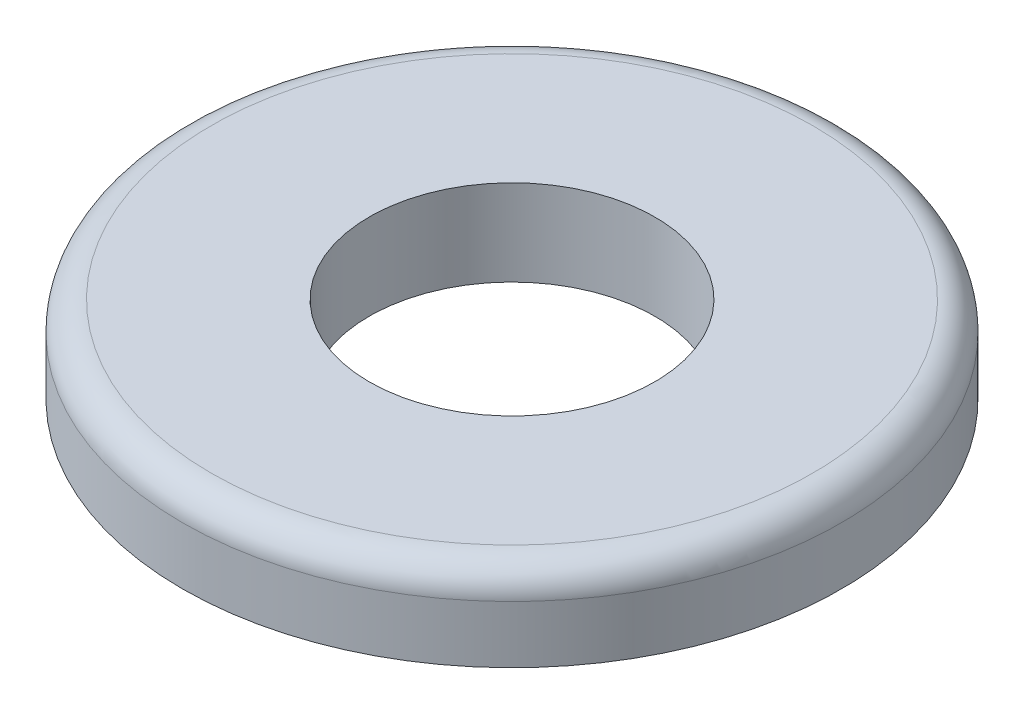
from build123d import *

# Parameters (mm, degrees)
SKETCH1_R           = 18.25625
SKETCH1_R_2         = 7.9121
BOSS_EXTRUDE1_DEPTH = 4.7625
FILLET1_R           = 1.5875


with BuildPart() as part:
    # Sketch1 → Boss-Extrude1 (new body)
    with BuildSketch(Plane(origin=(0, 0, 0), x_dir=(1, 0, 0), z_dir=(0, 1, 0))):
        Circle(SKETCH1_R)
        Circle(SKETCH1_R_2, mode=Mode.SUBTRACT)
    extrude(amount=BOSS_EXTRUDE1_DEPTH)

    # Fillet1
    fillet1_edges = [part.edges().sort_by_distance(p)[0] for p in [
        (-18.25625, 4.7625, 0),
    ]]
    fillet(fillet1_edges, radius=FILLET1_R)


solid = part.part
